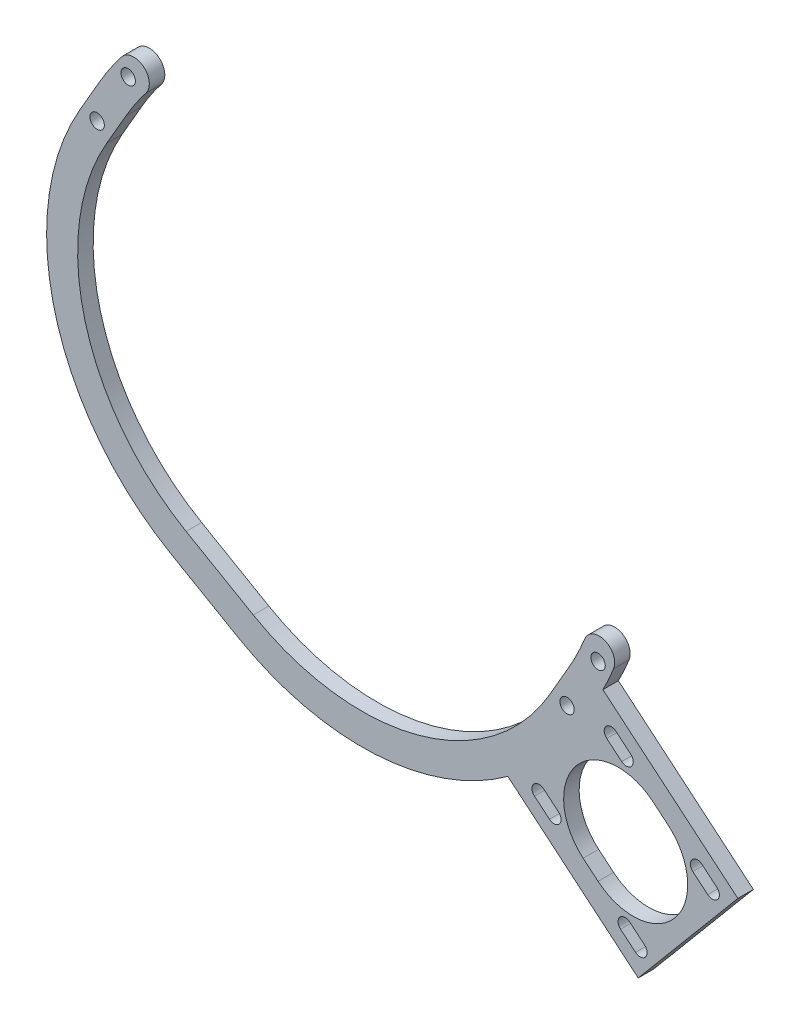
from build123d import *

# Parameters (mm, degrees)
BOSS_EXTRUDE1_DEPTH   = 3.175
BOSS_EXTRUDE2_DEPTH   = 3.175
F_4_CLEARANCE_HOLE1_D = 2.9464


with BuildPart() as part:
    # Sketch1 → Boss-Extrude1 (new body)
    with BuildSketch(Plane(origin=(0, 0, -14.15699402), x_dir=(-1, 0, 0), z_dir=(0, 0, -1))):
        with BuildLine():
            Line((-49.172312317, -34.502108483), (-53.141062317, -27.628031841))
            ThreePointArc((-53.141062317, -27.628031841), (-55.063803638, -24.012221257), (-56.72992661, -20.271224785))
            ThreePointArc((-56.72992661, -20.271224785), (-54.976138042, -16.13776671), (-50.842679967, -17.891555277))
            ThreePointArc((-50.842679967, -17.891555277), (-49.356678398, -21.228119699), (-47.641801003, -24.453031841))
            Line((-47.641801003, -24.453031841), (-43.673051003, -31.327108483))
            ThreePointArc((-43.673051003, -31.327108483), (-16.68272836, -52.037511462), (17.046778195, -47.596937682))
            Line((17.046778195, -47.596937682), (23.920854837, -43.628187682))
            Line((23.920854837, -43.628187682), (30.79493148, -39.659437682))
            ThreePointArc((30.79493148, -39.659437682), (51.505334458, -12.669115038), (47.064760678, 21.060391517))
            Line((47.064760678, 21.060391517), (43.096010678, 27.934468159))
            ThreePointArc((43.096010678, 27.934468159), (41.160593535, 31.032051618), (39.01404477, 33.987248938))
            ThreePointArc((39.01404477, 33.987248938), (39.561948355, 38.44382292), (44.018522337, 37.895919335))
            ThreePointArc((44.018522337, 37.895919335), (46.425258832, 34.58251628), (48.595271992, 31.109468159))
            Line((48.595271992, 31.109468159), (52.564021992, 24.235391517))
            ThreePointArc((52.564021992, 24.235391517), (57.638963455, -14.312615975), (33.96993148, -45.158698996))
            Line((33.96993148, -45.158698996), (27.095854837, -49.127448996))
            Line((27.095854837, -49.127448996), (20.221778195, -53.096198996))
            ThreePointArc((20.221778195, -53.096198996), (-18.326229296, -58.171140459), (-49.172312317, -34.502108483))
        make_face()
    extrude(amount=BOSS_EXTRUDE1_DEPTH)

    # Sketch6 → Boss-Extrude2 (add)
    with BuildSketch(Plane.XY.offset(-14.15699402)):
        Polygon((82.197110068, -48.248224024), (61.788603461, -72.570135093), (31.367040987, -47.043413242), (51.775547595, -22.721502173), align=None)
        with BuildLine():
            Line((64.875367382, -39.847664977), (67.930199412, -42.410973407))
            ThreePointArc((67.930199412, -42.410973407), (69.307717782, -58.156080429), (53.56261076, -59.533598799))
            Line((53.56261076, -59.533598799), (50.50777873, -56.970290369))
            ThreePointArc((50.50777873, -56.970290369), (49.130260359, -41.225183347), (64.875367382, -39.847664977))
        make_face(mode=Mode.SUBTRACT)
        with BuildLine():
            Line((61.233994962, -68.291668614), (58.179162931, -65.728360184))
            ThreePointArc((58.179162931, -65.728360184), (58.000711688, -63.688653138), (60.040418734, -63.510201894))
            Line((60.040418734, -63.510201894), (63.095250764, -66.073510324))
            ThreePointArc((63.095250764, -66.073510324), (63.273702008, -68.11321737), (61.233994962, -68.291668614))
        make_face(mode=Mode.SUBTRACT)
        with BuildLine():
            Line((42.411897591, -48.718116305), (45.466729621, -51.281424735))
            ThreePointArc((45.466729621, -51.281424735), (45.645180865, -53.321131781), (43.605473819, -53.499583025))
            Line((43.605473819, -53.499583025), (40.550641788, -50.936274595))
            ThreePointArc((40.550641788, -50.936274595), (40.372190545, -48.896567549), (42.411897591, -48.718116305))
        make_face(mode=Mode.SUBTRACT)
        with BuildLine():
            Line((57.20398318, -31.089595162), (60.25881521, -33.652903592))
            ThreePointArc((60.25881521, -33.652903592), (60.437266454, -35.692610638), (58.397559408, -35.871061882))
            Line((58.397559408, -35.871061882), (55.342727378, -33.307753452))
            ThreePointArc((55.342727378, -33.307753452), (55.164276134, -31.268046406), (57.20398318, -31.089595162))
        make_face(mode=Mode.SUBTRACT)
        with BuildLine():
            Line((74.832504323, -45.881680752), (77.887336353, -48.444989181))
            ThreePointArc((77.887336353, -48.444989181), (78.065787597, -50.484696227), (76.026080551, -50.663147471))
            Line((76.026080551, -50.663147471), (72.97124852, -48.099839041))
            ThreePointArc((72.97124852, -48.099839041), (72.792797277, -46.060131995), (74.832504323, -45.881680752))
        make_face(mode=Mode.SUBTRACT)
    extrude(amount=-BOSS_EXTRUDE2_DEPTH)

    # 4 Clearance Hole1 (through all)
    with Locations(Plane(origin=(0, 0, -17.33199402), x_dir=(-1, 0, 0), z_dir=(0, 0, -1))):
        with Locations((-53.56643166, -20.541270527), (-47.21643166, -31.539793155), (42.670641335, 35.021229473), (49.020641335, 24.022706845)):
            Hole(F_4_CLEARANCE_HOLE1_D / 2)


solid = part.part
